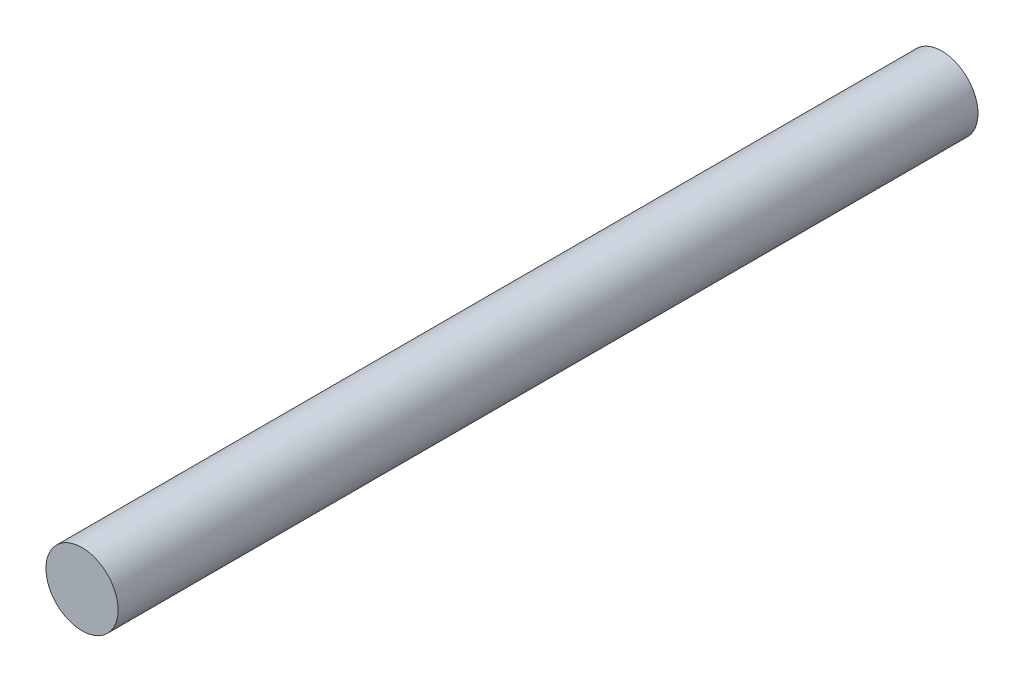
from build123d import *

# Parameters (mm, degrees)
SKETCH1_R           = 4.2625
BOSS_EXTRUDE1_DEPTH = 101.6


with BuildPart() as part:
    # Sketch1 → Boss-Extrude1 (new body)
    with BuildSketch(Plane.XY):
        Circle(SKETCH1_R)
    extrude(amount=BOSS_EXTRUDE1_DEPTH)


solid = part.part
